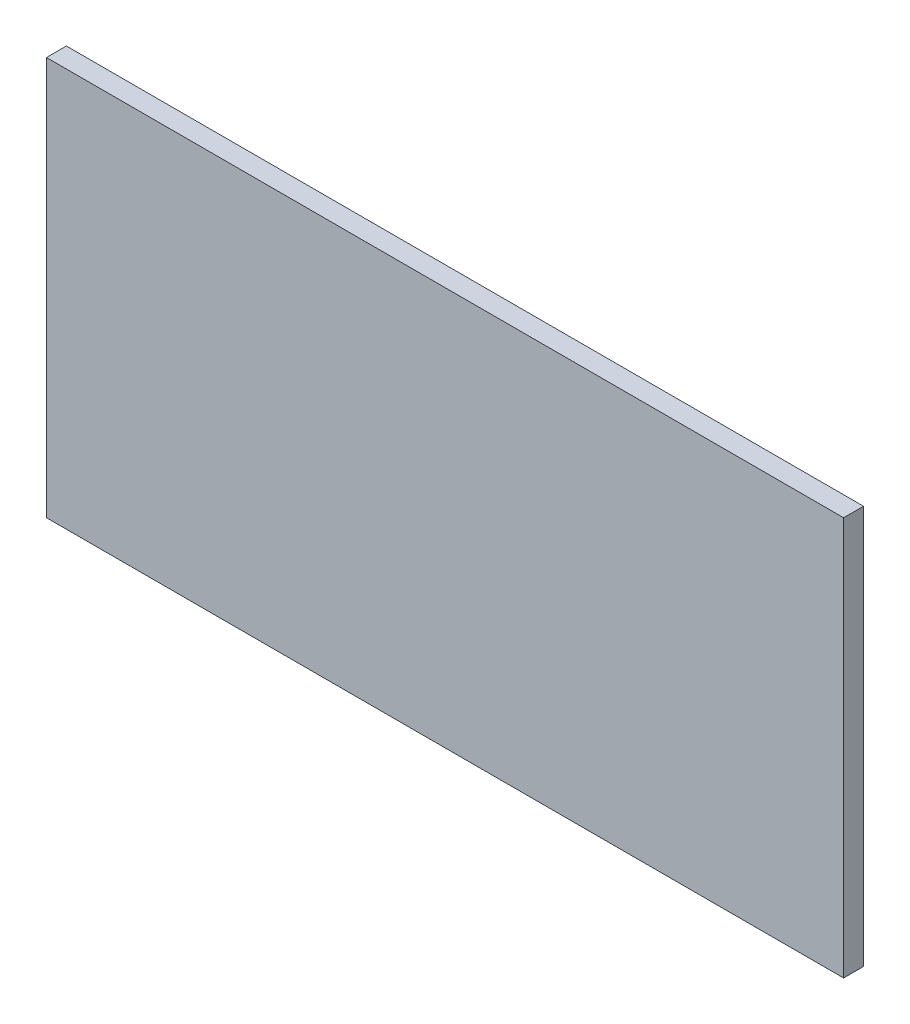
from build123d import *

# Parameters (mm, degrees)
SKETCH1_W           = 400
SKETCH1_H           = 200
BOSS_EXTRUDE1_DEPTH = 10


with BuildPart() as part:
    # Sketch1 → Boss-Extrude1 (new body)
    with BuildSketch(Plane.XY):
        with Locations((200, 100)):
            Rectangle(SKETCH1_W, SKETCH1_H)
    extrude(amount=BOSS_EXTRUDE1_DEPTH)


solid = part.part
